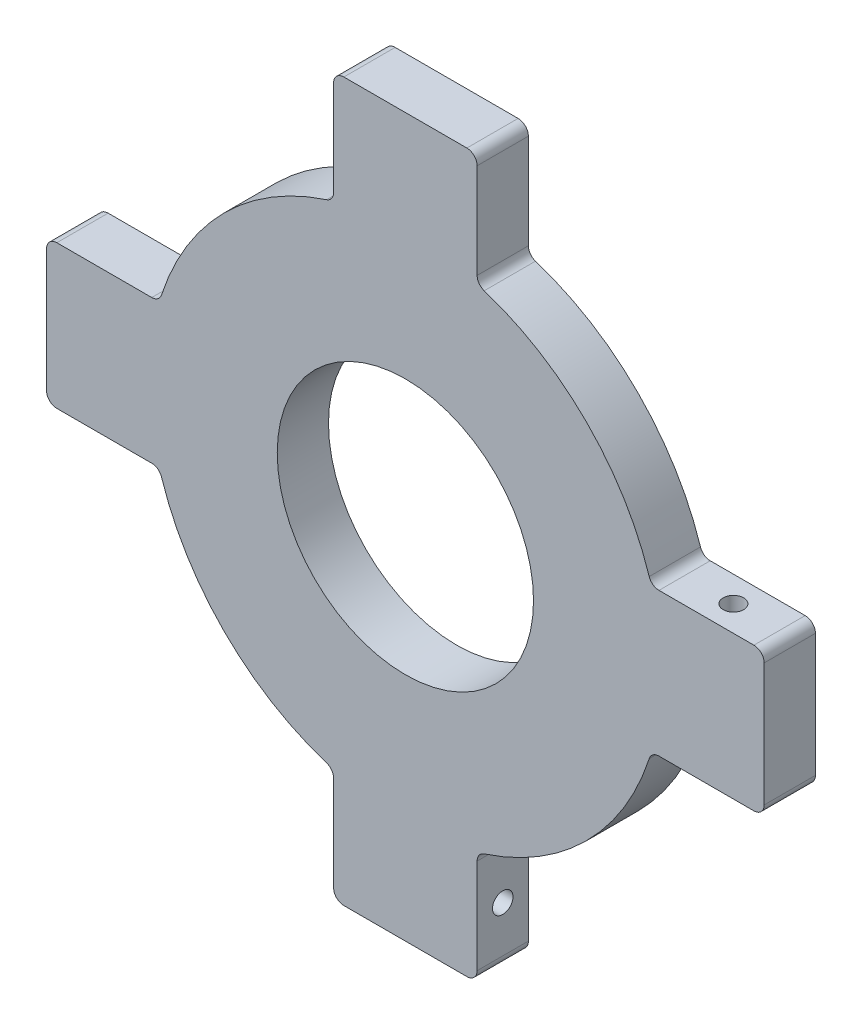
from build123d import *

# Parameters (mm, degrees)
SKETCH1_R           = 12.5
BOSS_EXTRUDE1_DEPTH = 5
SKETCH2_R           = 1
CUT_EXTRUDE1_DEPTH  = 3
CIRPATTERN1_COUNT   = 4
FILLET1_R           = 1
FILLET2_R           = 1


with BuildPart() as part:
    # Sketch1 → Boss-Extrude1 (new body)
    with BuildSketch(Plane.XY):
        with BuildLine():
            Line((35, 7), (24, 7))
            ThreePointArc((24, 7), (17.67766953, 17.67766953), (7, 24))
            Line((7, 24), (7, 35))
            Line((7, 35), (-7, 35))
            Line((-7, 35), (-7, 24))
            ThreePointArc((-7, 24), (-17.67766953, 17.67766953), (-24, 7))
            Line((-24, 7), (-35, 7))
            Line((-35, 7), (-35, -7))
            Line((-35, -7), (-24, -7))
            ThreePointArc((-24, -7), (-17.67766953, -17.67766953), (-7, -24))
            Line((-7, -24), (-7, -35))
            Line((-7, -35), (7, -35))
            Line((7, -35), (7, -24))
            ThreePointArc((7, -24), (17.67766953, -17.67766953), (24, -7))
            Line((24, -7), (35, -7))
            Line((35, -7), (35, 7))
        make_face()
        Circle(SKETCH1_R, mode=Mode.SUBTRACT)
    extrude(amount=BOSS_EXTRUDE1_DEPTH)

    # Sketch2 → Cut-Extrude1 (cut)
    with BuildSketch(Plane(origin=(0, 7, 0), x_dir=(1, 0, 0), z_dir=(0, 1, 0))):
        with Locations((29.5, -2.5)):
            Circle(SKETCH2_R)
    cut_extrude1 = extrude(amount=-CUT_EXTRUDE1_DEPTH, mode=Mode.SUBTRACT)

    # CirPattern1: Cut-Extrude1 ×4 about axis
    cirpattern1_axis = Axis((0, 0, 0), (0, 0, 1))
    for i in range(1, CIRPATTERN1_COUNT):
        add(cut_extrude1.rotate(cirpattern1_axis, i * 360 / CIRPATTERN1_COUNT), mode=Mode.SUBTRACT)

    # Fillet1
    fillet1_edges = [part.edges().sort_by_distance(p)[0] for p in [
        (35, 7, 2.5),
        (35, -7, 2.5),
        (7, -35, 2.5),
        (-7, -35, 2.5),
        (-35, -7, 2.5),
        (-35, 7, 2.5),
        (-7, 35, 2.5),
        (7, 35, 2.5),
    ]]
    fillet(fillet1_edges, radius=FILLET1_R)

    # Fillet2
    fillet2_edges = [part.edges().sort_by_distance(p)[0] for p in [
        (24, 7, 2.5),
        (24, -7, 2.5),
        (7, -24, 2.5),
        (-7, -24, 2.5),
        (-24, -7, 2.5),
        (-24, 7, 2.5),
        (-7, 24, 2.5),
        (7, 24, 2.5),
    ]]
    fillet(fillet2_edges, radius=FILLET2_R)


solid = part.part
